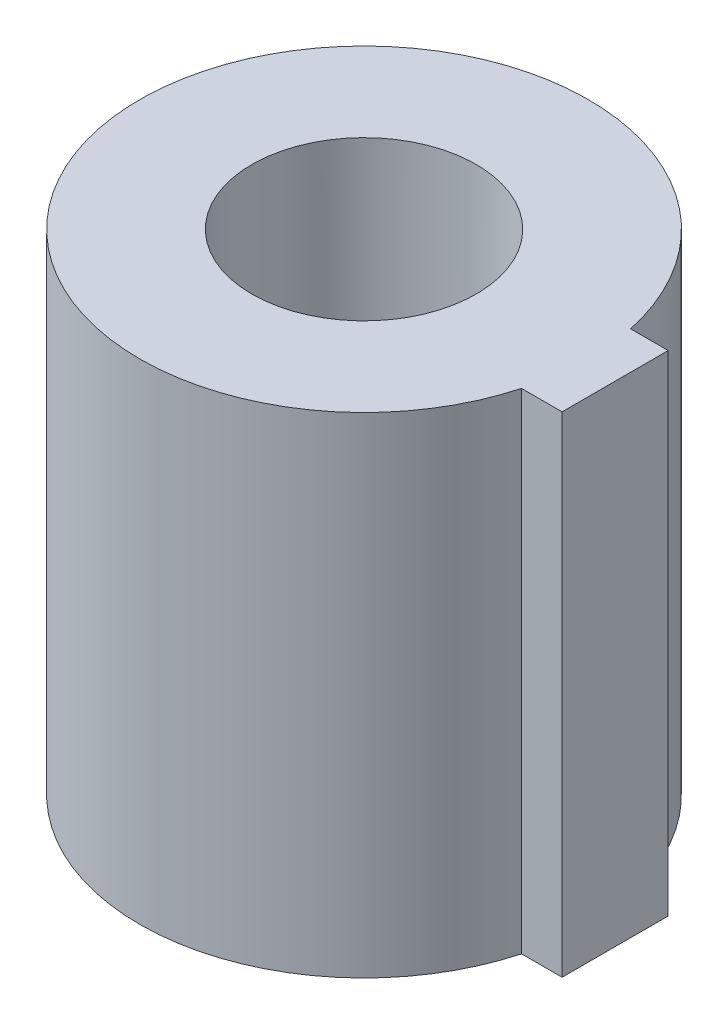
from build123d import *

# Parameters (mm, degrees)
SKETCH1_R           = 5.5
BOSS_EXTRUDE1_DEPTH = 12
SKETCH2_W           = 3
SKETCH2_H           = 2.6
BOSS_EXTRUDE2_DEPTH = 12
CUT_EXTRUDE1_DEPTH  = 3.8
SKETCH5_R           = 2.75
CUT_EXTRUDE3_DEPTH  = 17.65


with BuildPart() as part:
    # Sketch1 → Boss-Extrude1 (new body)
    with BuildSketch(Plane(origin=(0, 0, 0), x_dir=(1, 0, 0), z_dir=(0, 1, 0))):
        Circle(SKETCH1_R)
    extrude(amount=BOSS_EXTRUDE1_DEPTH)

    # Sketch2 → Boss-Extrude2 (add)
    with BuildSketch(Plane(origin=(0, 12, 0), x_dir=(1, 0, 0), z_dir=(0, 1, 0))):
        with Locations((4.8, -0.147270773)):
            Rectangle(SKETCH2_W, SKETCH2_H)
    extrude(amount=-BOSS_EXTRUDE2_DEPTH)

    # Sketch3 → Cut-Extrude1 (cut)
    with BuildSketch(Plane(origin=(0, 0, 0), x_dir=(-1, 0, 0), z_dir=(0, -1, 0))):
        Polygon((-1.891599986, 4.086789631), (-4.485063634, 0.405221174), (-2.593463648, -3.681568458), (1.891599986, -4.086789631), (4.485063634, -0.405221174), (2.593463648, 3.681568458), align=None)
    extrude(amount=-CUT_EXTRUDE1_DEPTH, mode=Mode.SUBTRACT)

    # Sketch5 → Cut-Extrude3 (cut)
    with BuildSketch(Plane(origin=(0, 12, 0), x_dir=(1, 0, 0), z_dir=(0, 1, 0))):
        Circle(SKETCH5_R)
    extrude(amount=-CUT_EXTRUDE3_DEPTH, mode=Mode.SUBTRACT)


solid = part.part
